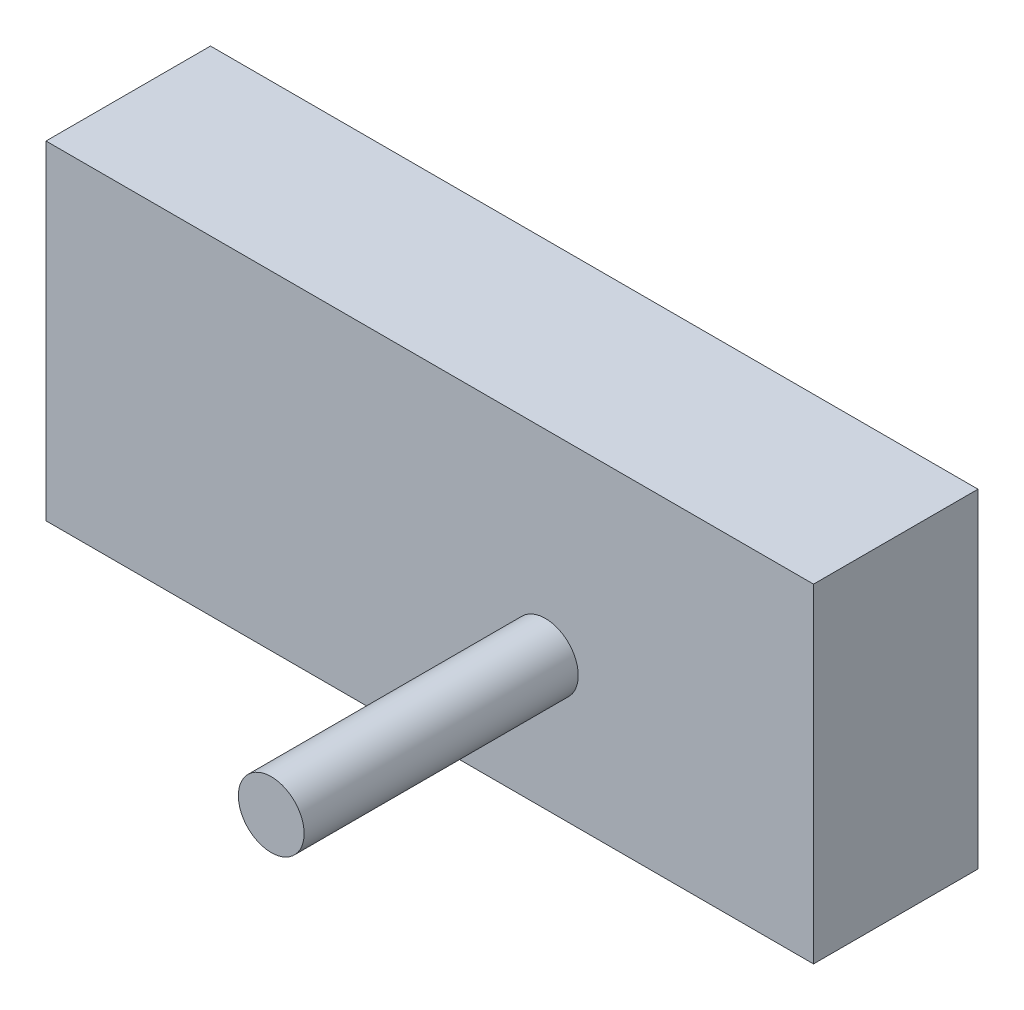
from build123d import *

# Parameters (mm, degrees)
IZIM2_W                     = 140
IZIM2_H                     = 60
Y_KSEKLIK_EKSTR_ZYON2_DEPTH = 30
IZIM3_R                     = 6
Y_KSEKLIK_EKSTR_ZYON3_DEPTH = 50


with BuildPart() as part:
    # Çizim2 → Yükseklik-Ekstrüzyon2 (new body)
    with BuildSketch(Plane.XY):
        with Locations((22.258064516, -0.161290323)):
            Rectangle(IZIM2_W, IZIM2_H)
    extrude(amount=Y_KSEKLIK_EKSTR_ZYON2_DEPTH)

    # Çizim3 → Yükseklik-Ekstrüzyon3 (add)
    with BuildSketch(Plane.XY.offset(30)):
        with Locations((43.342230404, -6.03131378)):
            Circle(IZIM3_R)
    extrude(amount=Y_KSEKLIK_EKSTR_ZYON3_DEPTH)


solid = part.part
